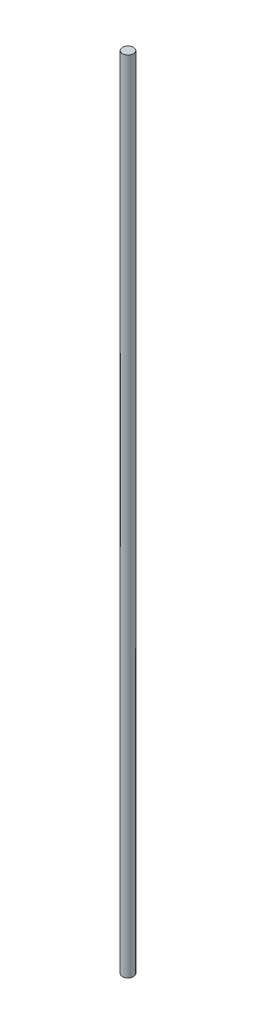
from build123d import *

# Parameters (mm, degrees)
CROQUIS1_R = 6.35


with BuildPart() as part:
    # Barrer1: sweep along a path in Croquis2
    with BuildLine(Plane.XY) as barrer1_path:
        Line((0, 0), (0, 920))
    # Croquis1 → Barrer1 (sweep)
    with BuildSketch(Plane(origin=(0, 0, 0), x_dir=(1, 0, 0), z_dir=(0, 1, 0))):
        Circle(CROQUIS1_R)
    sweep(path=barrer1_path.line)


solid = part.part
